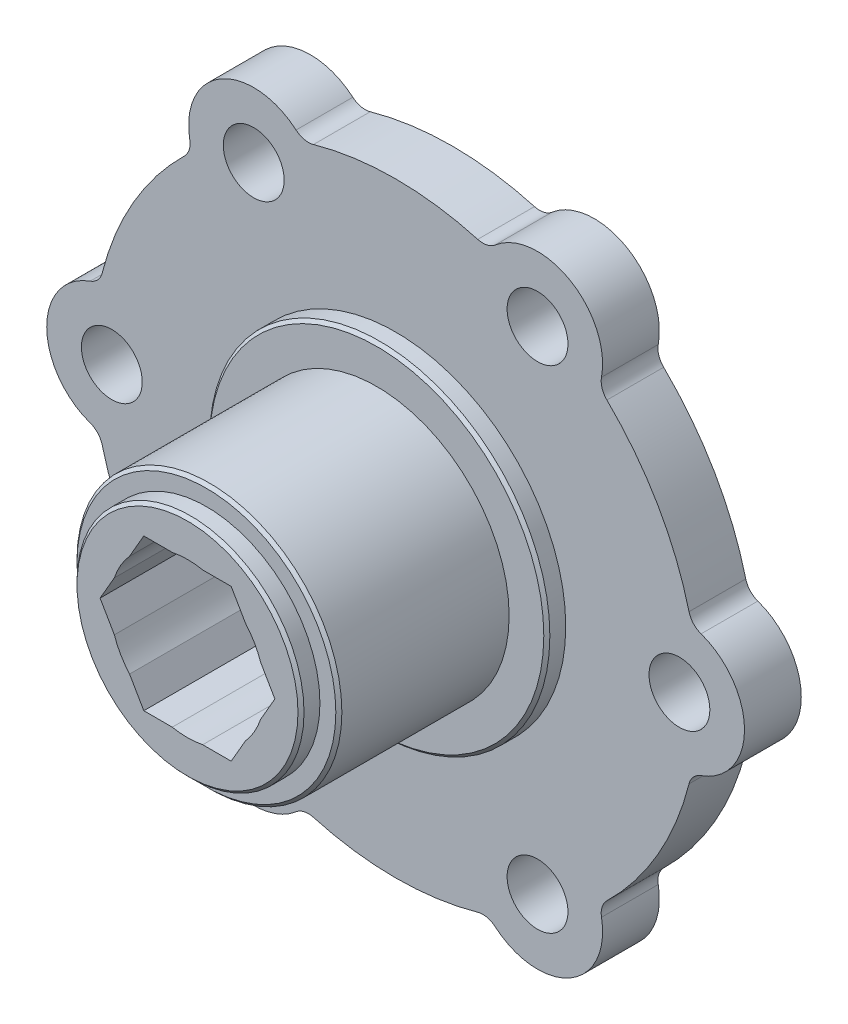
from build123d import *

# Parameters (mm, degrees)
BOSS_EXTRUDE1_DEPTH            = 4.7625
BOSS_EXTRUDE2_DEPTH            = 4.7625
BOSS_EXTRUDE3_DEPTH            = 4.7625
BOSS_EXTRUDE4_DEPTH            = 4.7625
BOSS_EXTRUDE5_DEPTH            = 4.7625
BOSS_EXTRUDE6_DEPTH            = 4.7625
SKETCH7_R                      = 14.2748
BOSS_EXTRUDE7_DEPTH            = 1.5875
SKETCH8_R                      = 11.1125
BOSS_EXTRUDE8_DEPTH            = 14.2875
SKETCH9_R                      = 9.525
BOSS_EXTRUDE9_DEPTH            = 1.5875
SKETCH10_R                     = 14.2748
BOSS_EXTRUDE10_DEPTH           = 1.5875
SKETCH11_R                     = 9.525
BOSS_EXTRUDE11_DEPTH           = 1.5875
CUT_EXTRUDE1_DEPTH             = 26.4
F_7_0_201_DIAMETER_HOLE1_D     = 5.1054
F_7_0_201_DIAMETER_HOLE1_DEPTH = 7.9375
F_7_0_201_DIAMETER_HOLE2_D     = 5.1054
F_7_0_201_DIAMETER_HOLE2_DEPTH = 22.225
CHAMFER1_SIZE                  = 0.254
FILLET1_R                      = 1.5875


with BuildPart() as part:
    # Sketch1 → Boss-Extrude1 (new body)
    with BuildSketch(Plane.XY):
        with BuildLine():
            ThreePointArc((4.446778, 31.449222355), (0, 26.083229928), (4.446778, 20.7172375))
            ThreePointArc((4.446778, 20.7172375), (54.6735, 26.083229928), (4.446778, 31.449222355))
        make_face()
    extrude(amount=-BOSS_EXTRUDE1_DEPTH)

    # Sketch2 → Boss-Extrude2 (add)
    with BuildSketch(Plane.XY):
        with BuildLine():
            ThreePointArc((21.507224759, 1.899661769), (16.5735, 4.086184671), (12.213053241, 7.265654197))
            ThreePointArc((12.213053241, 7.265654197), (14.63675, 0.73163527), (21.507224759, 1.899661769))
        make_face()
    extrude(amount=-BOSS_EXTRUDE2_DEPTH)

    # Sketch3 → Boss-Extrude3 (add)
    with BuildSketch(Plane.XY):
        with BuildLine():
            ThreePointArc((46.333946759, 7.265654197), (41.9735, 4.086184671), (37.039775241, 1.899661769))
            ThreePointArc((37.039775241, 1.899661769), (43.91025, 0.73163527), (46.333946759, 7.265654197))
        make_face()
    extrude(amount=-BOSS_EXTRUDE3_DEPTH)

    # Sketch4 → Boss-Extrude4 (add)
    with BuildSketch(Plane.XY):
        with BuildLine():
            ThreePointArc((54.100222, 31.449222355), (54.6735, 26.083229928), (54.100222, 20.7172375))
            ThreePointArc((54.100222, 20.7172375), (58.547, 26.083229928), (54.100222, 31.449222355))
        make_face()
    extrude(amount=-BOSS_EXTRUDE4_DEPTH)

    # Sketch5 → Boss-Extrude5 (add)
    with BuildSketch(Plane.XY):
        with BuildLine():
            ThreePointArc((37.039775241, 50.266798086), (41.9735, 48.080275184), (46.333946759, 44.900805658))
            ThreePointArc((46.333946759, 44.900805658), (43.91025, 51.434824585), (37.039775241, 50.266798086))
        make_face()
    extrude(amount=-BOSS_EXTRUDE5_DEPTH)

    # Sketch6 → Boss-Extrude6 (add)
    with BuildSketch(Plane(origin=(0, 0, -4.7625), x_dir=(-1, 0, 0), z_dir=(0, 0, -1))):
        with BuildLine():
            ThreePointArc((-12.213053241, 44.900805658), (-14.63675, 51.434824585), (-21.507224759, 50.266798086))
            ThreePointArc((-21.507224759, 50.266798086), (-16.5735, 48.080275184), (-12.213053241, 44.900805658))
        make_face()
    extrude(amount=-BOSS_EXTRUDE6_DEPTH)

    # Sketch7 → Boss-Extrude7 (add)
    with BuildSketch(Plane.XY):
        with Locations((29.2735, 26.083229928)):
            Circle(SKETCH7_R)
    extrude(amount=BOSS_EXTRUDE7_DEPTH)

    # Sketch8 → Boss-Extrude8 (add)
    with BuildSketch(Plane.XY.offset(1.5875)):
        with Locations((29.2735, 26.083229928)):
            Circle(SKETCH8_R)
    extrude(amount=BOSS_EXTRUDE8_DEPTH)

    # Sketch9 → Boss-Extrude9 (add)
    with BuildSketch(Plane.XY.offset(15.875)):
        with Locations((29.2735, 26.083229928)):
            Circle(SKETCH9_R)
    extrude(amount=BOSS_EXTRUDE9_DEPTH)

    # Sketch10 → Boss-Extrude10 (add)
    with BuildSketch(Plane(origin=(0, 0, -4.7625), x_dir=(-1, 0, 0), z_dir=(0, 0, -1))):
        with Locations((-29.2735, 26.083229928)):
            Circle(SKETCH10_R)
    extrude(amount=BOSS_EXTRUDE10_DEPTH)

    # Sketch11 → Boss-Extrude11 (add)
    with BuildSketch(Plane(origin=(0, 0, -6.35), x_dir=(-1, 0, 0), z_dir=(0, 0, -1))):
        with Locations((-29.2735, 26.083229928)):
            Circle(SKETCH11_R)
    extrude(amount=BOSS_EXTRUDE11_DEPTH)

    # Sketch12 → Cut-Extrude1 (cut, through all)
    with BuildSketch(Plane(origin=(0, 0, -7.9375), x_dir=(-1, 0, 0), z_dir=(0, 0, -1))):
        with BuildLine():
            Line((-24.412405788, 30.363567772), (-25.607325791, 32.433229928))
            Line((-25.607325791, 32.433229928), (-27.997165796, 32.433229928))
            ThreePointArc((-27.997165796, 32.433229928), (-29.2735, 32.560229928), (-30.549834204, 32.433229928))
            Line((-30.549834204, 32.433229928), (-32.939674209, 32.433229928))
            Line((-32.939674209, 32.433229928), (-34.134594212, 30.363567772))
            ThreePointArc((-34.134594212, 30.363567772), (-34.88274654, 29.321729928), (-35.410928416, 28.152892083))
            Line((-35.410928416, 28.152892083), (-36.605848419, 26.083229928))
            Line((-36.605848419, 26.083229928), (-35.410928416, 24.013567772))
            ThreePointArc((-35.410928416, 24.013567772), (-34.88274654, 22.844729928), (-34.134594212, 21.802892083))
            Line((-34.134594212, 21.802892083), (-32.939674209, 19.733229928))
            Line((-32.939674209, 19.733229928), (-30.549834204, 19.733229928))
            ThreePointArc((-30.549834204, 19.733229928), (-29.2735, 19.606229928), (-27.997165796, 19.733229928))
            Line((-27.997165796, 19.733229928), (-25.607325791, 19.733229928))
            Line((-25.607325791, 19.733229928), (-24.412405788, 21.802892083))
            ThreePointArc((-24.412405788, 21.802892083), (-23.66425346, 22.844729928), (-23.136071584, 24.013567772))
            Line((-23.136071584, 24.013567772), (-21.941151581, 26.083229928))
            Line((-21.941151581, 26.083229928), (-23.136071584, 28.152892083))
            ThreePointArc((-23.136071584, 28.152892083), (-23.66425346, 29.321729928), (-24.412405788, 30.363567772))
        make_face()
    extrude(amount=-CUT_EXTRUDE1_DEPTH, mode=Mode.SUBTRACT)

    # #7 (0.201) Diameter Hole1
    with Locations(Plane.XY):
        with Locations((41.17975, 46.705459855), (53.086, 26.083229928), (41.17975, 5.461), (17.36725, 5.461), (5.461, 26.083229928)):
            Hole(F_7_0_201_DIAMETER_HOLE1_D / 2, depth=F_7_0_201_DIAMETER_HOLE1_DEPTH)

    # #7 (0.201) Diameter Hole2
    with Locations(Plane(origin=(0, 0, -4.7625), x_dir=(-1, 0, 0), z_dir=(0, 0, -1))):
        with Locations((-17.36725, 46.705459855)):
            Hole(F_7_0_201_DIAMETER_HOLE2_D / 2, depth=F_7_0_201_DIAMETER_HOLE2_DEPTH)

    # Chamfer1
    chamfer1_edges = [part.edges().sort_by_distance(p)[0] for p in [
        (14.9987, 26.083229928, 1.5875),
        (18.161, 26.083229928, 15.875),
        (19.7485, 26.083229928, 17.4625),
        (43.5483, 26.083229928, -6.35),
        (38.7985, 26.083229928, -7.9375),
    ]]
    chamfer(chamfer1_edges, length=CHAMFER1_SIZE)

    # Fillet1
    fillet1_edges = [part.edges().sort_by_distance(p)[0] for p in [
        (21.507224759, 1.899661769, -2.38125),
        (12.213053241, 7.265654197, -2.38125),
        (46.333946759, 7.265654197, -2.38125),
        (37.039775241, 1.899661769, -2.38125),
        (54.100222, 31.449222355, -2.38125),
        (54.100222, 20.7172375, -2.38125),
        (37.039775241, 50.266798086, -2.38125),
        (46.333946759, 44.900805658, -2.38125),
        (12.213053241, 44.900805658, -2.38125),
        (21.507224759, 50.266798086, -2.38125),
        (4.446778, 20.7172375, -2.38125),
        (4.446778, 31.449222355, -2.38125),
    ]]
    fillet(fillet1_edges, radius=FILLET1_R)


solid = part.part
